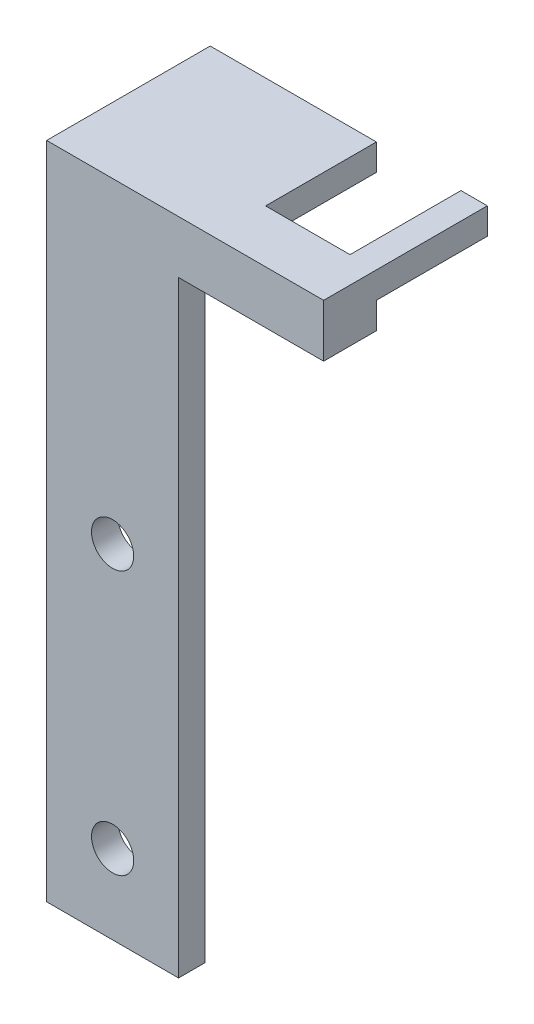
from build123d import *

# Parameters (mm, degrees)
SKETCH1_W           = 15.875
SKETCH1_H           = 79.375
SKETCH1_R           = 2.54
BOSS_EXTRUDE1_DEPTH = 3.175
BOSS_EXTRUDE2_DEPTH = 3.175
SKETCH3_W           = 17.4625
SKETCH3_H           = 3.175
BOSS_EXTRUDE3_DEPTH = 3.175


with BuildPart() as part:
    # Sketch1 → Boss-Extrude1 (new body)
    with BuildSketch(Plane.XY):
        with Locations((-8.404682644, -10.214522003)):
            Rectangle(SKETCH1_W, SKETCH1_H)
        with Locations((-8.404682644, -8.627022003)):
            Circle(SKETCH1_R, mode=Mode.SUBTRACT)
        with Locations((-8.404682644, -40.377022003)):
            Circle(SKETCH1_R, mode=Mode.SUBTRACT)
    extrude(amount=BOSS_EXTRUDE1_DEPTH)

    # Sketch2 → Boss-Extrude2 (add)
    with BuildSketch(Plane(origin=(0, 29.472977997, 0), x_dir=(1, 0, 0), z_dir=(0, 1, 0))):
        Polygon((-0.467182644, 0), (3.660317356, 0), (3.660317356, 3.175), (3.660317356, 16.51), (-16.342182644, 16.51), (-16.342182644, 0), align=None)
        Polygon((16.995317356, 0), (3.660317356, 0), (-0.467182644, 0), (-0.467182644, -3.175), (16.995317356, -3.175), align=None)
        Polygon((3.660317356, 3.175), (3.660317356, 0), (16.995317356, 0), (16.995317356, 16.531210472), (13.820317356, 16.531210472), (13.820317356, 3.175), align=None)
    extrude(amount=-BOSS_EXTRUDE2_DEPTH)

    # Sketch3 → Boss-Extrude3 (add)
    with BuildSketch(Plane.XZ.offset(-26.297977997)):
        Polygon((-0.467182644, 0), (-16.342182644, 0), (-16.342182644, -3.175), (3.660317356, -3.175), (13.820317356, -3.175), (16.995317356, -3.175), (16.995317356, 0), align=None)
        with Locations((8.264067356, 1.5875)):
            Rectangle(SKETCH3_W, SKETCH3_H)
    extrude(amount=BOSS_EXTRUDE3_DEPTH)


solid = part.part
